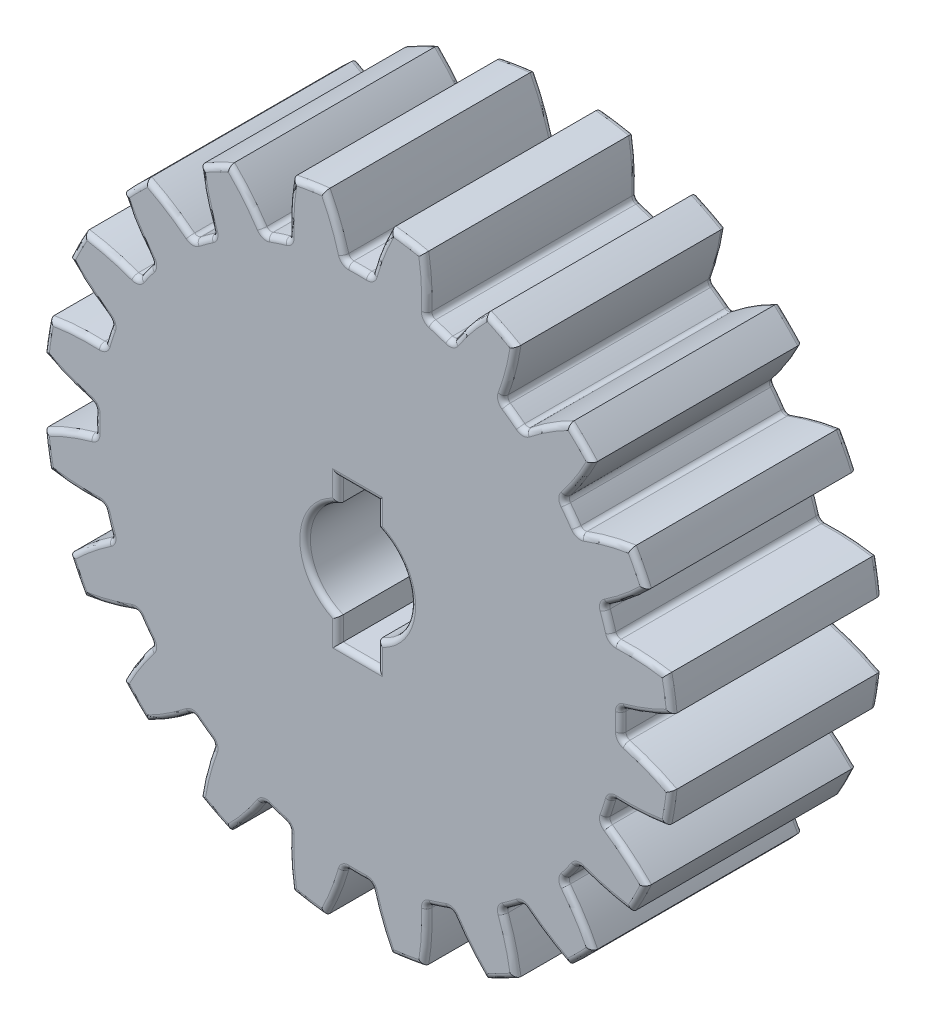
from build123d import *

# Parameters (mm, degrees)
SKETCH2_R                = 12
BOSS_EXTRUDE2_DEPTH      = 8
BOSS_EXTRUDE4_DEPTH      = 2
BOSS_EXTRUDE4_DEPTH_BACK = 1
SKETCH2_6_R              = 5
SKETCH2_6_R_2            = 4
BOSS_EXTRUDE5_START      = 3
SKETCH2_7_R              = 5
SKETCH2_7_R_2            = 4
BOSS_EXTRUDE5_DEPTH      = 3
CUT_EXTRUDE1_DEPTH       = 19.761663039
CIRPATTERN1_COUNT        = 20
FILLET3_R                = 0.2


with BuildPart() as part:
    # Sketch2 → Boss-Extrude2 (new body)
    with BuildSketch(Plane.XY):
        Circle(SKETCH2_R)
        with BuildLine():
            Line((-0.75, -2.75), (-0.75, -1.854049622))
            ThreePointArc((-0.75, -1.854049622), (-2, 0), (-0.75, 1.854049622))
            Line((-0.75, 1.854049622), (-0.75, 2.75))
            Line((-0.75, 2.75), (0.75, 2.75))
            Line((0.75, 2.75), (0.75, 1.854049622))
            ThreePointArc((0.75, 1.854049622), (2, 0), (0.75, -1.854049622))
            Line((0.75, -1.854049622), (0.75, -2.75))
            Line((0.75, -2.75), (-0.75, -2.75))
        make_face(mode=Mode.SUBTRACT)
    extrude(amount=BOSS_EXTRUDE2_DEPTH)

    # Sketch2_6 → Boss-Extrude4 (add, two sides: drawn at the far end of the back side and taken through both)
    with BuildSketch(Plane.XY.offset(-BOSS_EXTRUDE4_DEPTH_BACK)):
        Circle(SKETCH2_6_R)
        Circle(SKETCH2_6_R_2, mode=Mode.SUBTRACT)
    extrude(amount=BOSS_EXTRUDE4_DEPTH + BOSS_EXTRUDE4_DEPTH_BACK)

    # Sketch2_7 → Boss-Extrude5 (add)
    with BuildSketch(Plane.XY.offset(BOSS_EXTRUDE5_START)):
        Circle(SKETCH2_7_R)
        Circle(SKETCH2_7_R_2, mode=Mode.SUBTRACT)
    extrude(amount=-BOSS_EXTRUDE5_DEPTH)

    # Sketch3 → Cut-Extrude1 (cut, symmetric)
    with BuildSketch(Plane(origin=(0, 0, 0), x_dir=(-1, 0, 0), z_dir=(0, 0, -1))):
        with BuildLine():
            ThreePointArc((-0.34114768, 9.994179219), (0, 10), (0.34114768, 9.994179219))
            ThreePointArc((0.34114768, 9.994179219), (0.466373391, 10.032877236), (0.540748033, 10.140800485))
            ThreePointArc((0.540748033, 10.140800485), (2.412287307, 13.635783176), (5.603993944, 15.9875))
            ThreePointArc((5.603993944, 15.9875), (0, 16.634883756), (-5.603993944, 15.9875))
            ThreePointArc((-5.603993944, 15.9875), (-2.412287307, 13.635783176), (-0.540748033, 10.140800485))
            ThreePointArc((-0.540748033, 10.140800485), (-0.466373391, 10.032877236), (-0.34114768, 9.994179219))
        make_face()
    cut_extrude1 = extrude(amount=CUT_EXTRUDE1_DEPTH, both=True, mode=Mode.SUBTRACT)

    # CirPattern1: Cut-Extrude1 ×20 about axis
    cirpattern1_axis = Axis((0, 0, 8), (0, 0, -1))
    for i in range(1, CIRPATTERN1_COUNT):
        add(cut_extrude1.rotate(cirpattern1_axis, i * 360 / CIRPATTERN1_COUNT), mode=Mode.SUBTRACT)

    # Fillet3
    fillet3_edges = [part.edges().sort_by_distance(p)[0] for p in [
        (-8.485281374, 8.485281374, 8),
        (-7.184757163, 8.446920141, 8),
        (-6.274481276, 7.842640785, 8),
        (-5.877852523, 8.090169944, 8),
        (-5.519873278, 8.390895587, 8),
        (-5.813286378, 9.443351992, 8),
        (-5.447885997, 10.69207829, 8),
        (-4.222868245, 10.253710506, 8),
        (-3.543877021, 9.397715969, 8),
        (-3.090169944, 9.510565163, 8),
        (-2.656782116, 9.685950576, 8),
        (-2.610607642, 10.777565732, 8),
        (-1.87721358, 11.852260087, 8),
        (-0.84761556, 11.056796246, 8),
        (-0.466373391, 10.032877236, 8),
        (0, 10, 8),
        (0.466373391, 10.032877236, 8),
        (0.84761556, 11.056796246, 8),
        (1.87721358, 11.852260087, 8),
        (2.610607642, 10.777565732, 8),
        (2.656782116, 9.685950576, 8),
        (3.090169944, 9.510565163, 8),
        (3.543877021, 9.397715969, 8),
        (4.222868245, 10.253710506, 8),
        (5.447885997, 10.69207829, 8),
        (5.813286378, 9.443351992, 8),
        (5.519873278, 8.390895587, 8),
        (5.877852523, 8.090169944, 8),
        (6.274481276, 7.842640785, 8),
        (7.184757163, 8.446920141, 8),
        (8.485281374, 8.485281374, 8),
        (8.446920141, 7.184757163, 8),
        (7.842640785, 6.274481276, 8),
        (8.090169944, 5.877852523, 8),
        (8.390895587, 5.519873278, 8),
        (9.443351992, 5.813286378, 8),
        (10.69207829, 5.447885997, 8),
        (10.253710506, 4.222868245, 8),
        (9.397715969, 3.543877021, 8),
        (9.510565163, 3.090169944, 8),
        (9.685950576, 2.656782116, 8),
        (10.777565732, 2.610607642, 8),
        (11.852260087, 1.87721358, 8),
        (11.056796246, 0.84761556, 8),
        (10.032877236, 0.466373391, 8),
        (10, 0, 8),
        (10.032877236, -0.466373391, 8),
        (11.056796246, -0.84761556, 8),
        (11.852260087, -1.87721358, 8),
        (10.777565732, -2.610607642, 8),
        (9.685950576, -2.656782116, 8),
        (9.510565163, -3.090169944, 8),
        (9.397715969, -3.543877021, 8),
        (10.253710506, -4.222868245, 8),
        (10.69207829, -5.447885997, 8),
        (9.443351992, -5.813286378, 8),
        (8.390895587, -5.519873278, 8),
        (8.090169944, -5.877852523, 8),
        (7.842640785, -6.274481276, 8),
        (8.446920141, -7.184757163, 8),
        (8.485281374, -8.485281374, 8),
        (7.184757163, -8.446920141, 8),
        (6.274481276, -7.842640785, 8),
        (5.877852523, -8.090169944, 8),
        (5.519873278, -8.390895587, 8),
        (5.813286378, -9.443351992, 8),
        (5.447885997, -10.69207829, 8),
        (4.222868245, -10.253710506, 8),
        (3.543877021, -9.397715969, 8),
        (3.090169944, -9.510565163, 8),
        (2.656782116, -9.685950576, 8),
        (2.610607642, -10.777565732, 8),
        (1.87721358, -11.852260087, 8),
        (0.84761556, -11.056796246, 8),
        (0.466373391, -10.032877236, 8),
        (0, -10, 8),
        (-0.466373391, -10.032877236, 8),
        (-0.84761556, -11.056796246, 8),
        (-1.87721358, -11.852260087, 8),
        (-2.610607642, -10.777565732, 8),
        (-2.656782116, -9.685950576, 8),
        (-3.090169944, -9.510565163, 8),
        (-3.543877021, -9.397715969, 8),
        (-4.222868245, -10.253710506, 8),
        (-5.447885997, -10.69207829, 8),
        (-5.813286378, -9.443351992, 8),
        (-5.519873278, -8.390895587, 8),
        (-5.877852523, -8.090169944, 8),
        (-6.274481276, -7.842640785, 8),
        (-7.184757163, -8.446920141, 8),
        (-8.485281374, -8.485281374, 8),
        (-8.446920141, -7.184757163, 8),
        (-7.842640785, -6.274481276, 8),
        (-8.090169944, -5.877852523, 8),
        (-8.390895587, -5.519873278, 8),
        (-9.443351992, -5.813286378, 8),
        (-10.69207829, -5.447885997, 8),
        (-10.253710506, -4.222868245, 8),
        (-9.397715969, -3.543877021, 8),
        (-9.510565163, -3.090169944, 8),
        (-9.685950576, -2.656782116, 8),
        (-10.777565732, -2.610607642, 8),
        (-11.852260087, -1.87721358, 8),
        (-11.056796246, -0.84761556, 8),
        (-10.032877236, -0.466373391, 8),
        (-10, 0, 8),
        (-10.032877236, 0.466373391, 8),
        (-11.056796246, 0.84761556, 8),
        (-11.852260087, 1.87721358, 8),
        (-10.777565732, 2.610607642, 8),
        (-9.685950576, 2.656782116, 8),
        (-9.510565163, 3.090169944, 8),
        (-9.397715969, 3.543877021, 8),
        (-10.253710506, 4.222868245, 8),
        (-10.69207829, 5.447885997, 8),
        (-9.443351992, 5.813286378, 8),
        (-8.390895587, 5.519873278, 8),
        (-8.090169944, 5.877852523, 8),
        (-7.842640785, 6.274481276, 8),
        (-8.446920141, 7.184757163, 8),
        (-0.75, -2.302024811, 8),
        (0, -2.75, 8),
        (0.75, -2.302024811, 8),
        (2, 0, 8),
        (0.75, 2.302024811, 8),
        (0, 2.75, 8),
        (-0.75, 2.302024811, 8),
        (-2, 0, 8),
        (-4, 0, 0),
        (-0.75, 2.302024811, 0),
        (0, 2.75, 0),
        (0.75, 2.302024811, 0),
        (2, 0, 0),
        (0.75, -2.302024811, 0),
        (0, -2.75, 0),
        (-0.75, -2.302024811, 0),
        (-2, 0, 0),
        (-5, 0, -1),
        (-4, 0, -1),
        (-8.090169944, 5.877852523, 0),
        (-8.390895587, 5.519873278, 0),
        (-9.443351992, 5.813286378, 0),
        (-10.69207829, 5.447885997, 0),
        (-10.253710506, 4.222868245, 0),
        (-9.397715969, 3.543877021, 0),
        (-9.510565163, 3.090169944, 0),
        (-9.685950576, 2.656782116, 0),
        (-10.777565732, 2.610607642, 0),
        (-11.852260087, 1.87721358, 0),
        (-11.056796246, 0.84761556, 0),
        (-10.032877236, 0.466373391, 0),
        (-10, 0, 0),
        (-10.032877236, -0.466373391, 0),
        (-11.056796246, -0.84761556, 0),
        (-11.852260087, -1.87721358, 0),
        (-10.777565732, -2.610607642, 0),
        (-9.685950576, -2.656782116, 0),
        (-9.510565163, -3.090169944, 0),
        (-9.397715969, -3.543877021, 0),
        (-10.253710506, -4.222868245, 0),
        (-10.69207829, -5.447885997, 0),
        (-9.443351992, -5.813286378, 0),
        (-8.390895587, -5.519873278, 0),
        (-8.090169944, -5.877852523, 0),
        (-7.842640785, -6.274481276, 0),
        (-8.446920141, -7.184757163, 0),
        (-8.485281374, -8.485281374, 0),
        (-7.184757163, -8.446920141, 0),
        (-6.274481276, -7.842640785, 0),
        (-5.877852523, -8.090169944, 0),
        (-5.519873278, -8.390895587, 0),
        (-5.813286378, -9.443351992, 0),
        (-5.447885997, -10.69207829, 0),
        (-4.222868245, -10.253710506, 0),
        (-3.543877021, -9.397715969, 0),
        (-3.090169944, -9.510565163, 0),
        (-2.656782116, -9.685950576, 0),
        (-2.610607642, -10.777565732, 0),
        (-1.87721358, -11.852260087, 0),
        (-0.84761556, -11.056796246, 0),
        (-0.466373391, -10.032877236, 0),
        (0, -10, 0),
        (0.466373391, -10.032877236, 0),
        (0.84761556, -11.056796246, 0),
        (1.87721358, -11.852260087, 0),
        (2.610607642, -10.777565732, 0),
        (2.656782116, -9.685950576, 0),
        (3.090169944, -9.510565163, 0),
        (3.543877021, -9.397715969, 0),
        (4.222868245, -10.253710506, 0),
        (5.447885997, -10.69207829, 0),
        (5.813286378, -9.443351992, 0),
        (5.519873278, -8.390895587, 0),
        (5.877852523, -8.090169944, 0),
        (6.274481276, -7.842640785, 0),
        (7.184757163, -8.446920141, 0),
        (8.485281374, -8.485281374, 0),
        (8.446920141, -7.184757163, 0),
        (7.842640785, -6.274481276, 0),
        (8.090169944, -5.877852523, 0),
        (8.390895587, -5.519873278, 0),
        (9.443351992, -5.813286378, 0),
        (10.69207829, -5.447885997, 0),
        (10.253710506, -4.222868245, 0),
        (9.397715969, -3.543877021, 0),
        (9.510565163, -3.090169944, 0),
        (9.685950576, -2.656782116, 0),
        (10.777565732, -2.610607642, 0),
        (11.852260087, -1.87721358, 0),
        (11.056796246, -0.84761556, 0),
        (10.032877236, -0.466373391, 0),
        (10, 0, 0),
        (10.032877236, 0.466373391, 0),
        (11.056796246, 0.84761556, 0),
        (11.852260087, 1.87721358, 0),
        (10.777565732, 2.610607642, 0),
        (9.685950576, 2.656782116, 0),
        (9.510565163, 3.090169944, 0),
        (9.397715969, 3.543877021, 0),
        (10.253710506, 4.222868245, 0),
        (10.69207829, 5.447885997, 0),
        (9.443351992, 5.813286378, 0),
        (8.390895587, 5.519873278, 0),
        (8.090169944, 5.877852523, 0),
        (7.842640785, 6.274481276, 0),
        (8.446920141, 7.184757163, 0),
        (8.485281374, 8.485281374, 0),
        (7.184757163, 8.446920141, 0),
        (6.274481276, 7.842640785, 0),
        (5.877852523, 8.090169944, 0),
        (5.519873278, 8.390895587, 0),
        (5.813286378, 9.443351992, 0),
        (5.447885997, 10.69207829, 0),
        (4.222868245, 10.253710506, 0),
        (3.543877021, 9.397715969, 0),
        (3.090169944, 9.510565163, 0),
        (2.656782116, 9.685950576, 0),
        (2.610607642, 10.777565732, 0),
        (1.87721358, 11.852260087, 0),
        (0.84761556, 11.056796246, 0),
        (0.466373391, 10.032877236, 0),
        (0, 10, 0),
        (-0.466373391, 10.032877236, 0),
        (-0.84761556, 11.056796246, 0),
        (-1.87721358, 11.852260087, 0),
        (-2.610607642, 10.777565732, 0),
        (-2.656782116, 9.685950576, 0),
        (-3.090169944, 9.510565163, 0),
        (-3.543877021, 9.397715969, 0),
        (-4.222868245, 10.253710506, 0),
        (-5.447885997, 10.69207829, 0),
        (-5.813286378, 9.443351992, 0),
        (-5.519873278, 8.390895587, 0),
        (-5.877852523, 8.090169944, 0),
        (-6.274481276, 7.842640785, 0),
        (-7.184757163, 8.446920141, 0),
        (-8.485281374, 8.485281374, 0),
        (-8.446920141, 7.184757163, 0),
        (-7.842640785, 6.274481276, 0),
        (-5, 0, 0),
    ]]
    fillet(fillet3_edges, radius=FILLET3_R)


solid = part.part
